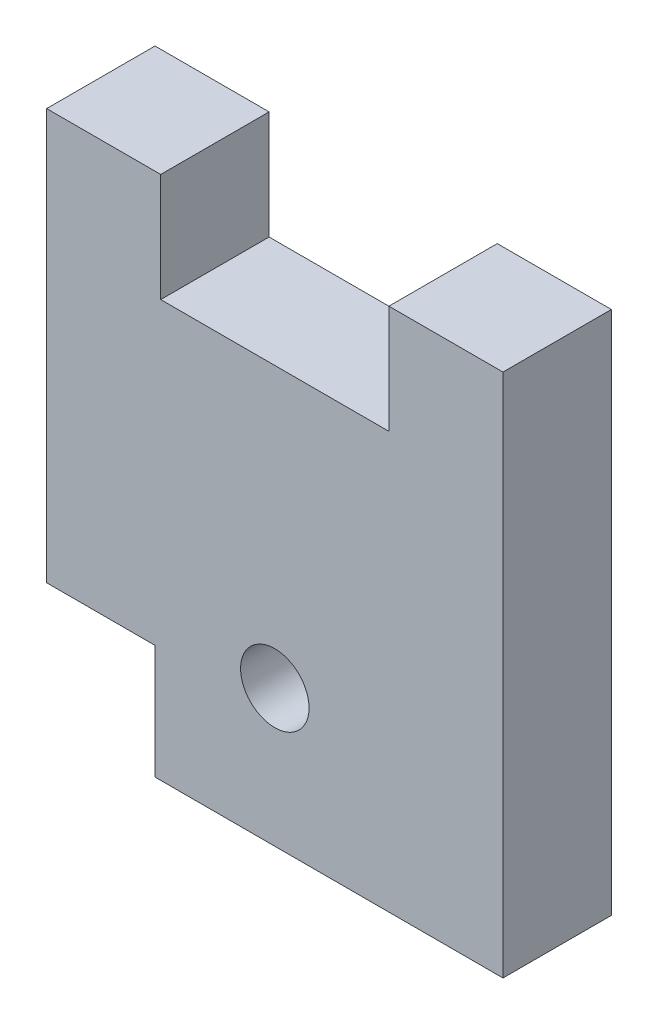
from build123d import *

# Parameters (mm, degrees)
SKETCH1_R           = 1.5
BOSS_EXTRUDE1_DEPTH = 4.75


with BuildPart() as part:
    # Sketch1 → Boss-Extrude1 (new body)
    with BuildSketch(Plane.XY):
        Polygon((15, 0), (20, 0), (20, -23), (4.75, -23), (4.75, -18), (0, -18), (0, 0), (5, 0), (5, -4.75), (15, -4.75), align=None)
        with Locations((10, -17)):
            Circle(SKETCH1_R, mode=Mode.SUBTRACT)
    extrude(amount=BOSS_EXTRUDE1_DEPTH)


solid = part.part
